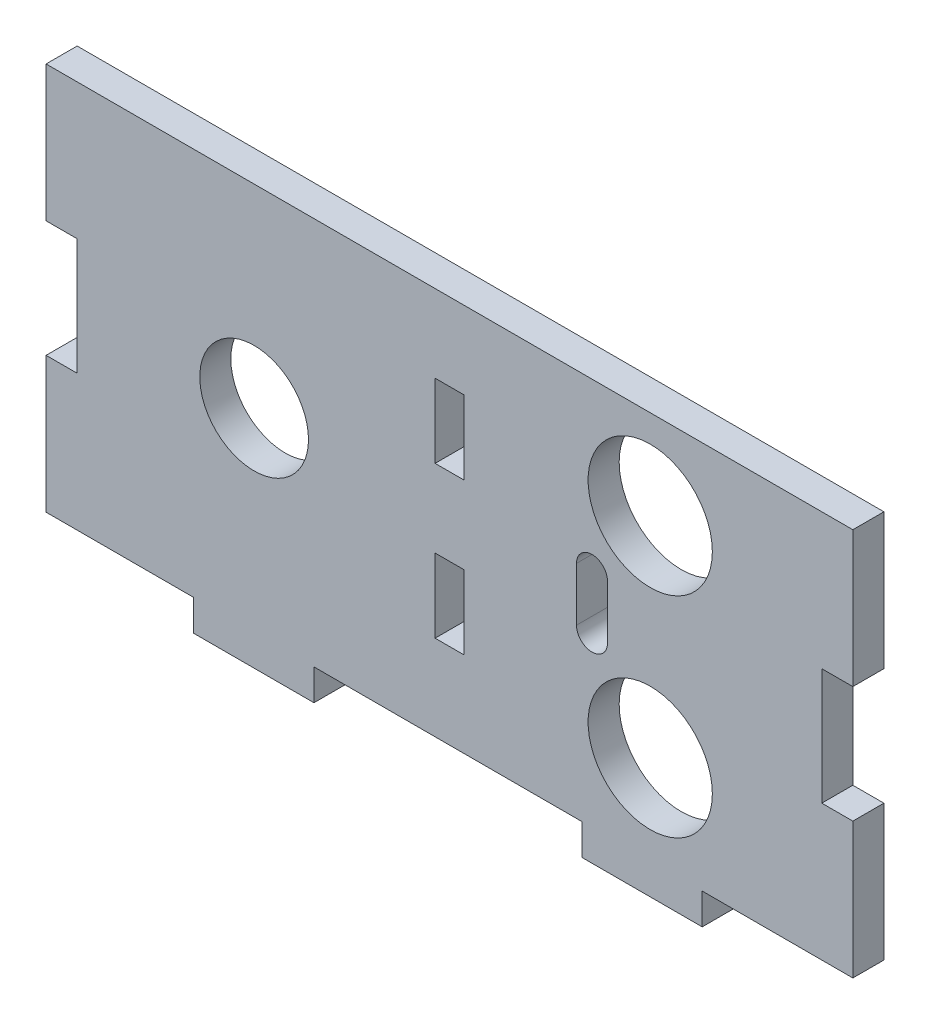
from build123d import *

# Parameters (mm, degrees)
SKIZZE1_W                       = 200
SKIZZE1_H                       = 50
AUFSATZ_LINEAR_AUSTRAGEN1_DEPTH = 4
SKIZZE2_W                       = 15.5
SKIZZE2_H                       = 4
AUFSATZ_LINEAR_AUSTRAGEN2_DEPTH = 4
SCHNITT_LINEAR_AUSTRAGEN1_REACH = 6
SKIZZE4_W                       = 4
SKIZZE4_H                       = 15
SCHNITT_LINEAR_AUSTRAGEN2_REACH = 6
SKIZZE5_W                       = 3.7
SKIZZE5_H                       = 9.5
SCHNITT_LINEAR_AUSTRAGEN3_DEPTH = 4
SCHNITT_LINEAR_AUSTRAGEN4_REACH = 6
SKIZZE7_R                       = 8
SKIZZE7_R_2                     = 7


with BuildPart() as part:
    # Skizze1 → Aufsatz-Linear austragen1 (new body)
    with BuildSketch(Plane.XY):
        with Locations((100, 25)):
            Rectangle(SKIZZE1_W, SKIZZE1_H)
    extrude(amount=AUFSATZ_LINEAR_AUSTRAGEN1_DEPTH)

    # Skizze2 → Aufsatz-Linear austragen2 (add)
    with BuildSketch(Plane(origin=(0, 0, 4), x_dir=(-1, 0, 0), z_dir=(0, 0, -1))):
        with Locations((-174.8, -2)):
            Rectangle(SKIZZE2_W, SKIZZE2_H)
        with Locations((-124.8, -2)):
            Rectangle(SKIZZE2_W, SKIZZE2_H)
        with Locations((-74.8, -2)):
            Rectangle(SKIZZE2_W, SKIZZE2_H)
        with Locations((-24.8, -2)):
            Rectangle(SKIZZE2_W, SKIZZE2_H)
    extrude(amount=AUFSATZ_LINEAR_AUSTRAGEN2_DEPTH)

    # Skizze4 → Schnitt-Linear austragen1 (cut, up to next)
    with BuildSketch(Plane.XY.offset(4), mode=Mode.PRIVATE) as schnitt_linear_austragen1_sk1:
        with Locations((2, 25)):
            Rectangle(SKIZZE4_W, SKIZZE4_H)
    schnitt_linear_austragen1_tool1 = extrude(schnitt_linear_austragen1_sk1.sketch, amount=-SCHNITT_LINEAR_AUSTRAGEN1_REACH, mode=Mode.PRIVATE) & part.part
    add(schnitt_linear_austragen1_tool1.solids().sort_by_distance((2, 25, 4))[0], mode=Mode.SUBTRACT)
    # Skizze4 → Schnitt-Linear austragen1 (cut, up to next)
    with BuildSketch(Plane.XY.offset(4), mode=Mode.PRIVATE) as schnitt_linear_austragen1_sk2:
        with Locations((198, 25)):
            Rectangle(SKIZZE4_W, SKIZZE4_H)
    schnitt_linear_austragen1_tool2 = extrude(schnitt_linear_austragen1_sk2.sketch, amount=-SCHNITT_LINEAR_AUSTRAGEN1_REACH, mode=Mode.PRIVATE) & part.part
    add(schnitt_linear_austragen1_tool2.solids().sort_by_distance((198, 25, 4))[0], mode=Mode.SUBTRACT)

    # Skizze5 → Schnitt-Linear austragen2 (cut, up to next)
    with BuildSketch(Plane(origin=(0, 0, 0), x_dir=(-1, 0, 0), z_dir=(0, 0, -1)), mode=Mode.PRIVATE) as schnitt_linear_austragen2_sk1:
        with Locations((-100, 35.25)):
            Rectangle(SKIZZE5_W, SKIZZE5_H)
    schnitt_linear_austragen2_tool1 = extrude(schnitt_linear_austragen2_sk1.sketch, amount=-SCHNITT_LINEAR_AUSTRAGEN2_REACH, mode=Mode.PRIVATE) & part.part
    add(schnitt_linear_austragen2_tool1.solids().sort_by_distance((100, 35.25, 0))[0], mode=Mode.SUBTRACT)
    # Skizze5 → Schnitt-Linear austragen2 (cut, up to next)
    with BuildSketch(Plane(origin=(0, 0, 0), x_dir=(-1, 0, 0), z_dir=(0, 0, -1)), mode=Mode.PRIVATE) as schnitt_linear_austragen2_sk2:
        with Locations((-100, 15.75)):
            Rectangle(SKIZZE5_W, SKIZZE5_H)
    schnitt_linear_austragen2_tool2 = extrude(schnitt_linear_austragen2_sk2.sketch, amount=-SCHNITT_LINEAR_AUSTRAGEN2_REACH, mode=Mode.PRIVATE) & part.part
    add(schnitt_linear_austragen2_tool2.solids().sort_by_distance((100, 15.75, 0))[0], mode=Mode.SUBTRACT)

    # Skizze6 → Schnitt-Linear austragen3 (cut)
    with BuildSketch(Plane.XY.offset(4)):
        Polygon((52.05, 32.5), (48.05, 32.5), (48.05, 66.141635161), (-25.301318738, 66.141635161), (-25.301318738, -17.071359215), (48.05, -17.071359215), (48.05, 17.5), (52.05, 17.5), align=None)
    schnitt_linear_austragen3 = extrude(amount=-SCHNITT_LINEAR_AUSTRAGEN3_DEPTH, mode=Mode.SUBTRACT)

    # Spiegeln1: Schnitt-Linear austragen3 across plane
    add(schnitt_linear_austragen3.mirror(Plane.ZY.offset(-100)), mode=Mode.SUBTRACT)

    # Skizze7 → Schnitt-Linear austragen4 (cut, up to next)
    with BuildSketch(Plane.XY.offset(4), mode=Mode.PRIVATE) as schnitt_linear_austragen4_sk1:
        with Locations((125.855537029, 11.5)):
            Circle(SKIZZE7_R)
    schnitt_linear_austragen4_tool1 = extrude(schnitt_linear_austragen4_sk1.sketch, amount=-SCHNITT_LINEAR_AUSTRAGEN4_REACH, mode=Mode.PRIVATE) & part.part
    add(schnitt_linear_austragen4_tool1.solids().sort_by_distance((125.855537, 11.5, 4))[0], mode=Mode.SUBTRACT)
    # Skizze7 → Schnitt-Linear austragen4 (cut, up to next)
    with BuildSketch(Plane.XY.offset(4), mode=Mode.PRIVATE) as schnitt_linear_austragen4_sk2:
        with Locations((125.855537029, 38.5)):
            Circle(SKIZZE7_R)
    schnitt_linear_austragen4_tool2 = extrude(schnitt_linear_austragen4_sk2.sketch, amount=-SCHNITT_LINEAR_AUSTRAGEN4_REACH, mode=Mode.PRIVATE) & part.part
    add(schnitt_linear_austragen4_tool2.solids().sort_by_distance((125.855537, 38.5, 4))[0], mode=Mode.SUBTRACT)
    # Skizze7 → Schnitt-Linear austragen4 (cut, up to next)
    with BuildSketch(Plane.XY.offset(4), mode=Mode.PRIVATE) as schnitt_linear_austragen4_sk3:
        with Locations((74.842197302, 25)):
            Circle(SKIZZE7_R_2)
    schnitt_linear_austragen4_tool3 = extrude(schnitt_linear_austragen4_sk3.sketch, amount=-SCHNITT_LINEAR_AUSTRAGEN4_REACH, mode=Mode.PRIVATE) & part.part
    add(schnitt_linear_austragen4_tool3.solids().sort_by_distance((74.842197, 25, 4))[0], mode=Mode.SUBTRACT)
    # Skizze7 → Schnitt-Linear austragen4 (cut, up to next)
    with BuildSketch(Plane.XY.offset(4), mode=Mode.PRIVATE) as schnitt_linear_austragen4_sk4:
        with BuildLine():
            Line((120.354935265, 28.448963973), (120.354935265, 21.551036027))
            ThreePointArc((120.354935265, 21.551036027), (118.354935265, 19.551036027), (116.354935265, 21.551036027))
            Line((116.354935265, 21.551036027), (116.354935265, 28.448963973))
            ThreePointArc((116.354935265, 28.448963973), (118.354935265, 30.448963973), (120.354935265, 28.448963973))
        make_face()
    schnitt_linear_austragen4_tool4 = extrude(schnitt_linear_austragen4_sk4.sketch, amount=-SCHNITT_LINEAR_AUSTRAGEN4_REACH, mode=Mode.PRIVATE) & part.part
    add(schnitt_linear_austragen4_tool4.solids().sort_by_distance((118.354935, 25, 4))[0], mode=Mode.SUBTRACT)


solid = part.part
